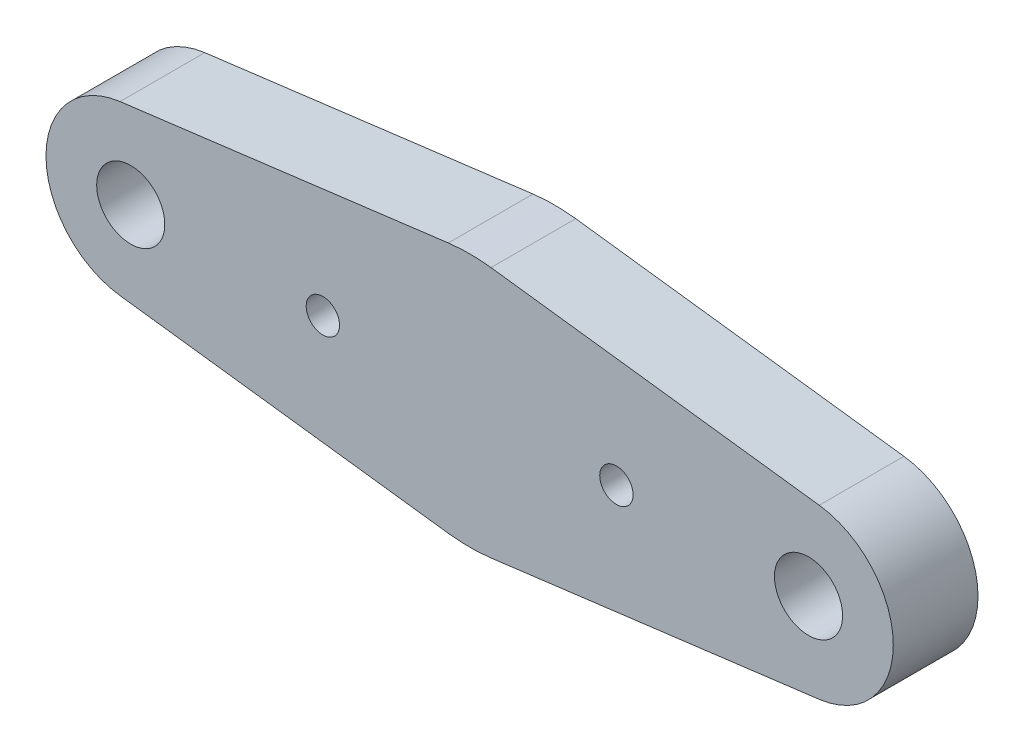
from build123d import *

# Parameters (mm, degrees)
BOSS_EXTRUDE1_DEPTH       = 6.35
M3X0_5_TAPPED_HOLE1_D     = 2.5
M3X0_5_TAPPED_HOLE1_DEPTH = 6.35
F_10_CLEARANCE_HOLE1_D    = 5.1054


with BuildPart() as part:
    # Sketch1 → Boss-Extrude1 (new body)
    with BuildSketch(Plane.XY):
        with BuildLine():
            Line((1.600151217, 9.423790263), (26.200075609, 6.299395131))
            ThreePointArc((26.200075609, 6.299395131), (31.75, 0), (26.200075609, -6.299395131))
            Line((26.200075609, -6.299395131), (1.600151217, -9.423790263))
            ThreePointArc((1.600151217, -9.423790263), (0, -9.525), (-1.600151217, -9.423790263))
            Line((-1.600151217, -9.423790263), (-26.200075609, -6.299395131))
            ThreePointArc((-26.200075609, -6.299395131), (-31.75, 0), (-26.200075609, 6.299395131))
            Line((-26.200075609, 6.299395131), (-1.600151217, 9.423790263))
            ThreePointArc((-1.600151217, 9.423790263), (0, 9.525), (1.600151217, 9.423790263))
        make_face()
    extrude(amount=BOSS_EXTRUDE1_DEPTH)

    # M3x0.5 Tapped Hole1
    with Locations(Plane(origin=(0, 0, 0), x_dir=(-1, 0, 0), z_dir=(0, 0, -1))):
        with Locations((-11, 0), (11, 0)):
            Hole(M3X0_5_TAPPED_HOLE1_D / 2, depth=M3X0_5_TAPPED_HOLE1_DEPTH)

    # #10 Clearance Hole1 (through all)
    with Locations(Plane(origin=(0, 0, 0), x_dir=(-1, 0, 0), z_dir=(0, 0, -1))):
        with Locations((25.4, 0), (-25.4, 0)):
            Hole(F_10_CLEARANCE_HOLE1_D / 2)


solid = part.part
